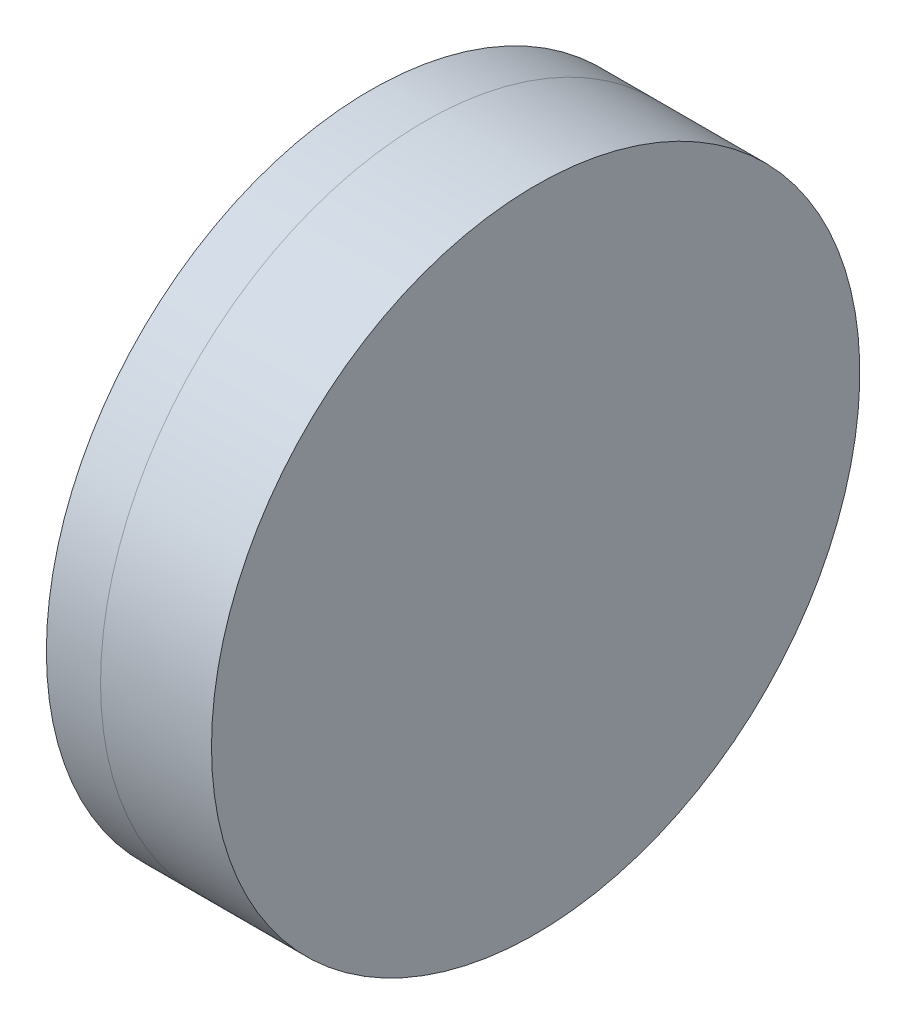
from build123d import *


with BuildPart() as part:
    # 草图1 one side → 旋转1 (revolve)
    with BuildSketch(Plane(origin=(0, 0, 0), x_dir=(1, 0, 0), z_dir=(0, 1, 0)), mode=Mode.PRIVATE) as revolve_1_sk:
        with BuildLine():
            ThreePointArc((336.300409734, 12.7), (335.57304983, 6.368505528), (335.330125938, 0))
            Line((335.330125938, 0), (339.330125938, 0))
            ThreePointArc((339.330125938, 0), (339.102991006, 6.366186986), (338.422741258, 12.7))
            Line((338.422741258, 12.7), (336.300409734, 12.7))
        make_face()
    revolve(revolve_1_sk.sketch.rotate(Axis((124.523309526, 0, 0), (1, 0, 0)), 180), axis=Axis((124.523309526, 0, 0), (1, 0, 0)))  # turned: the seam where the file's is


with BuildPart() as body_2:
    # 草图2 one side → 旋转3 (revolve)
    with BuildSketch(Plane(origin=(0, 0, 0), x_dir=(1, 0, 0), z_dir=(0, 1, 0)), mode=Mode.PRIVATE) as revolve_3_sk:
        with BuildLine():
            Line((342.769512006, 12.7), (338.422741258, 12.7))
            ThreePointArc((338.422741258, 12.7), (339.102991006, 6.366186986), (339.330125938, 0))
            Line((339.330125938, 0), (342.830125938, 0))
            ThreePointArc((342.830125938, 0), (342.814972369, 6.350072323), (342.769512006, 12.7))
        make_face()
    revolve(revolve_3_sk.sketch.rotate(Axis((-0.551919993, 0, 0), (1, 0, 0)), 180), axis=Axis((-0.551919993, 0, 0), (1, 0, 0)))  # turned: the seam where the file's is


solid = Compound([part.part, body_2.part])
